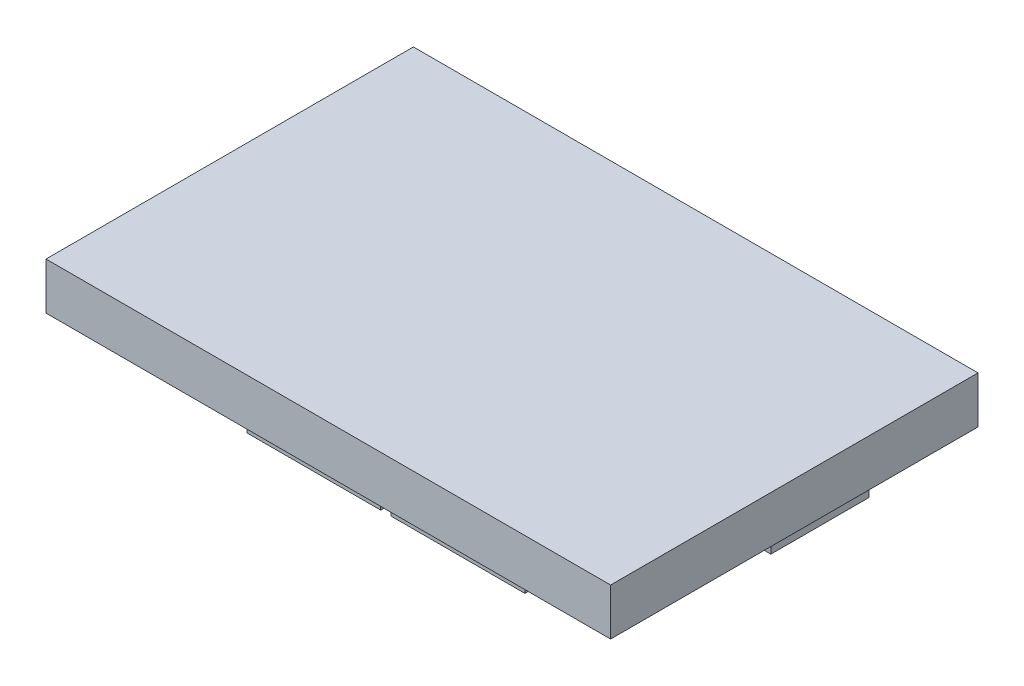
from build123d import *

# Parameters (mm, degrees)
SKETCH1_W           = 85.6
SKETCH1_H           = 55.7
BOSS_EXTRUDE1_DEPTH = 7.1
SKETCH2_W           = 20.3
SKETCH2_H           = 2.5
SKETCH2_W_2         = 15.3
BOSS_EXTRUDE2_DEPTH = 2.5
SKETCH3_W           = 15
SKETCH3_H           = 14.9
BOSS_EXTRUDE3_DEPTH = 2


with BuildPart() as part:
    # Sketch1 → Boss-Extrude1 (new body)
    with BuildSketch(Plane(origin=(0, 0, 0), x_dir=(1, 0, 0), z_dir=(0, 1, 0))):
        with Locations((42.8, 27.85)):
            Rectangle(SKETCH1_W, SKETCH1_H)
    extrude(amount=BOSS_EXTRUDE1_DEPTH)

    # Sketch2 → Boss-Extrude2 (add)
    with BuildSketch(Plane.XZ):
        with Locations((38.6, -3.25)):
            Rectangle(SKETCH2_W, SKETCH2_H)
        with Locations((60.45, -3.25)):
            Rectangle(SKETCH2_W, SKETCH2_H)
        with Locations((53.95, -51.95)):
            Rectangle(SKETCH2_W_2, SKETCH2_H)
        with Locations((36.1, -51.95)):
            Rectangle(SKETCH2_W_2, SKETCH2_H)
    extrude(amount=BOSS_EXTRUDE2_DEPTH)

    # Sketch3 → Boss-Extrude3 (add)
    with BuildSketch(Plane.XZ):
        with Locations((77.1, -32.75)):
            Rectangle(SKETCH3_W, SKETCH3_H)
    extrude(amount=BOSS_EXTRUDE3_DEPTH)


solid = part.part
